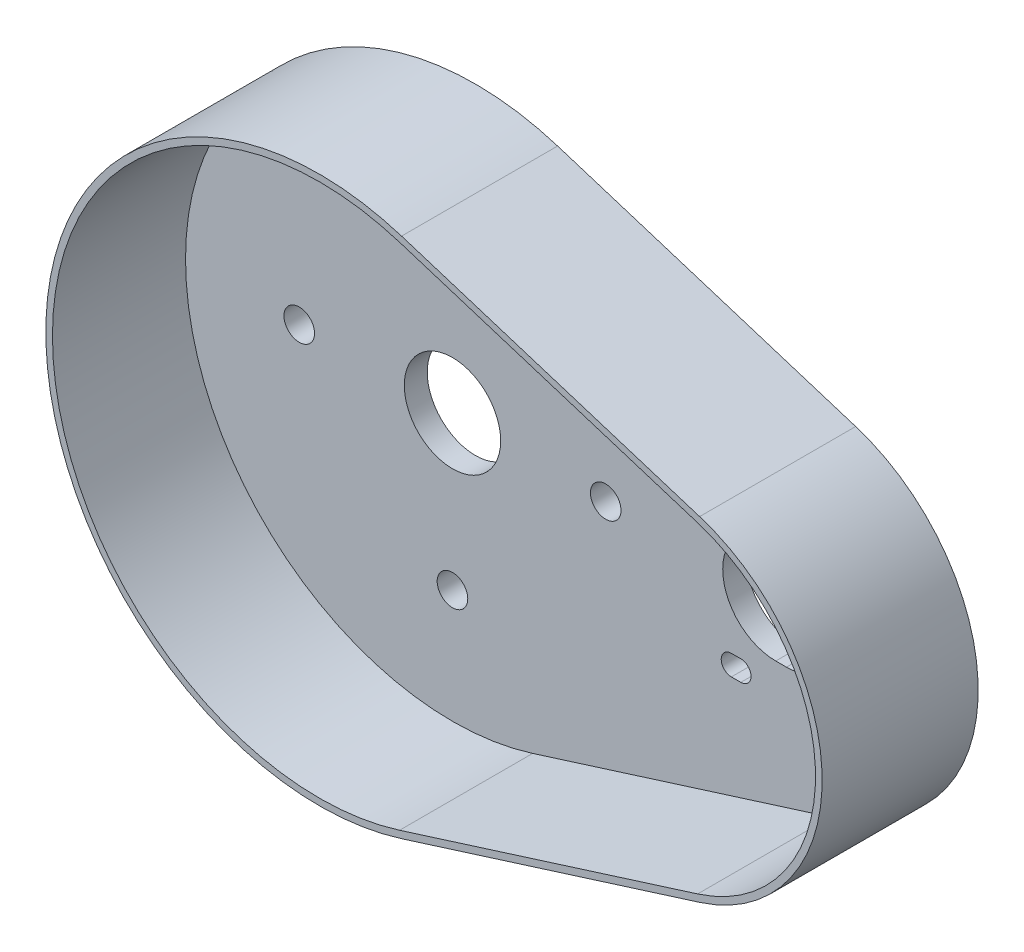
from build123d import *

# Parameters (mm, degrees)
SKETCH1_R           = 3
SKETCH1_R_2         = 9.45
BOSS_EXTRUDE1_DEPTH = 30.6
CUT_EXTRUDE1_DEPTH  = 26.1


with BuildPart() as part:
    # Sketch1 → Boss-Extrude1 (new body)
    with BuildSketch(Plane.XY):
        with BuildLine():
            ThreePointArc((74.571121214, -32.760854905), (98.6, 0), (74.571121214, 32.760854905))
            Line((74.571121214, 32.760854905), (16.117374778, 51.171796238))
            ThreePointArc((16.117374778, 51.171796238), (-53.65, 0), (16.117374778, -51.171796238))
            Line((16.117374778, -51.171796238), (74.571121214, -32.760854905))
        make_face()
        with BuildLine():
            Line((63.4, 10.4), (65.5, 10.4))
            ThreePointArc((65.5, 10.4), (75.9, 0), (65.5, -10.4))
            Line((65.5, -10.4), (63.4, -10.4))
            ThreePointArc((63.4, -10.4), (53, 0), (63.4, 10.4))
        make_face(mode=Mode.SUBTRACT)
        with Locations((30.05, 0)):
            Circle(SKETCH1_R, mode=Mode.SUBTRACT)
        with BuildLine():
            Line((56.551094978, -17.45), (54.701094978, -17.45))
            ThreePointArc((54.701094978, -17.45), (52.701094978, -15.45), (54.701094978, -13.45))
            Line((54.701094978, -13.45), (56.551094978, -13.45))
            ThreePointArc((56.551094978, -13.45), (58.551094978, -15.45), (56.551094978, -17.45))
        make_face(mode=Mode.SUBTRACT)
        with BuildLine():
            Line((87.601094978, -17.45), (85.751094978, -17.45))
            ThreePointArc((85.751094978, -17.45), (83.751094978, -15.45), (85.751094978, -13.45))
            Line((85.751094978, -13.45), (87.601094978, -13.45))
            ThreePointArc((87.601094978, -13.45), (89.601094978, -15.45), (87.601094978, -17.45))
        make_face(mode=Mode.SUBTRACT)
        with BuildLine():
            ThreePointArc((54.701094978, 13.45), (52.701094978, 15.45), (54.701094978, 17.45))
            Line((54.701094978, 17.45), (56.551094978, 17.45))
            ThreePointArc((56.551094978, 17.45), (58.551094978, 15.45), (56.551094978, 13.45))
            Line((56.551094978, 13.45), (54.701094978, 13.45))
        make_face(mode=Mode.SUBTRACT)
        with BuildLine():
            ThreePointArc((85.751094978, 13.45), (83.751094978, 15.45), (85.751094978, 17.45))
            Line((85.751094978, 17.45), (87.601094978, 17.45))
            ThreePointArc((87.601094978, 17.45), (89.601094978, 15.45), (87.601094978, 13.45))
            Line((87.601094978, 13.45), (85.751094978, 13.45))
        make_face(mode=Mode.SUBTRACT)
        Circle(SKETCH1_R_2, mode=Mode.SUBTRACT)
        with Locations((0, 30.05)):
            Circle(SKETCH1_R, mode=Mode.SUBTRACT)
        with Locations((0, -30.05)):
            Circle(SKETCH1_R, mode=Mode.SUBTRACT)
        with Locations((-30.05, 0)):
            Circle(SKETCH1_R, mode=Mode.SUBTRACT)
    extrude(amount=BOSS_EXTRUDE1_DEPTH)

    # Sketch2 → Cut-Extrude1 (cut)
    with BuildSketch(Plane.XY.offset(30.6)):
        with BuildLine():
            Line((74.180579048, 31.520904576), (15.726832612, 49.93184591))
            ThreePointArc((15.726832612, 49.93184591), (-52.35, 0), (15.726832612, -49.93184591))
            Line((15.726832612, -49.93184591), (74.180579048, -31.520904576))
            ThreePointArc((74.180579048, -31.520904576), (97.3, 0), (74.180579048, 31.520904576))
        make_face()
    extrude(amount=-CUT_EXTRUDE1_DEPTH, mode=Mode.SUBTRACT)


solid = part.part
